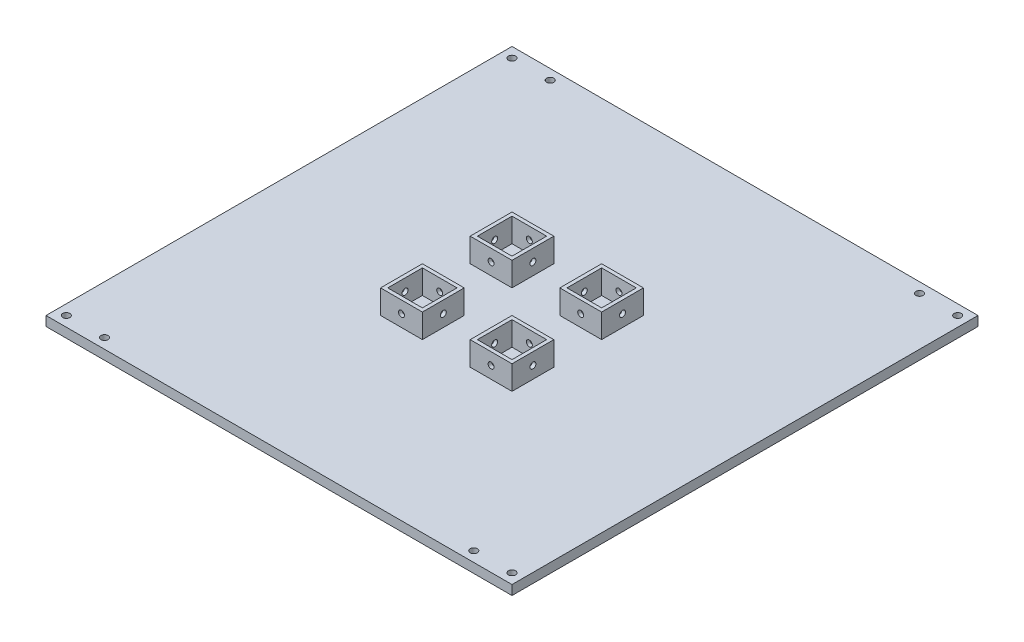
from build123d import *

# Parameters (mm, degrees)
SKETCH1_W                   = 195
SKETCH1_H                   = 195
BOSS_EXTRUDE1_DEPTH         = 4
SKETCH2_W                   = 17.5
SKETCH2_H                   = 17.5
BOSS_EXTRUDE2_DEPTH         = 10
SKETCH3_W                   = 14.5
SKETCH3_H                   = 14.5
CUT_EXTRUDE1_DEPTH          = 10
TAP_DRILL_FOR_M3X0_5_TAP1_D = 2.5
TAP_DRILL_FOR_M3X0_5_TAP2_D = 2.5
MIRROR2_COPY_1_SKETCH_W     = 17.5
MIRROR2_COPY_1_SKETCH_H     = 17.5
MIRROR2_COPY_1_DEPTH        = 10
MIRROR2_COPY_2_SKETCH_W     = 14.5
MIRROR2_COPY_2_SKETCH_H     = 14.5
MIRROR2_COPY_2_DEPTH        = 10
MIRROR2_COPY_3_D            = 2.5
MIRROR2_COPY_4_D            = 2.5
SKETCH8_R                   = 1.5
CUT_EXTRUDE2_DEPTH          = 4
MIRROR4_COPY_1_SKETCH_R     = 1.5
MIRROR4_COPY_1_DEPTH        = 4


with BuildPart() as part:
    # Sketch1 → Boss-Extrude1 (new body)
    with BuildSketch(Plane(origin=(0, 0, 0), x_dir=(1, 0, 0), z_dir=(0, 1, 0))):
        Rectangle(SKETCH1_W, SKETCH1_H)
    extrude(amount=BOSS_EXTRUDE1_DEPTH)

    # Sketch2 → Boss-Extrude2 (add)
    with BuildSketch(Plane(origin=(0, 4, 0), x_dir=(1, 0, 0), z_dir=(0, 1, 0))):
        with Locations((-18.75, 18.75)):
            Rectangle(SKETCH2_W, SKETCH2_H)
    boss_extrude2 = extrude(amount=BOSS_EXTRUDE2_DEPTH)

    # Sketch3 → Cut-Extrude1 (cut)
    with BuildSketch(Plane(origin=(0, 14, 0), x_dir=(1, 0, 0), z_dir=(0, 1, 0))):
        with Locations((-18.75, 18.75)):
            Rectangle(SKETCH3_W, SKETCH3_H)
    cut_extrude1 = extrude(amount=-CUT_EXTRUDE1_DEPTH, mode=Mode.SUBTRACT)

    # Tap Drill for M3x0.5 Tap1 (through all)
    with Locations(Plane.XY.offset(-10)):
        with Locations((-18.75, 9)):
            tap_drill_for_m3x0_5_tap1 = Hole(TAP_DRILL_FOR_M3X0_5_TAP1_D / 2)

    # Tap Drill for M3x0.5 Tap2 (through all)
    with Locations(Plane.ZY.offset(27.5)):
        with Locations((-18.75, 9)):
            tap_drill_for_m3x0_5_tap2 = Hole(TAP_DRILL_FOR_M3X0_5_TAP2_D / 2)

    # Mirror1: Boss-Extrude2, Cut-Extrude1, Tap Drill for M3x0.5 Tap1, Tap Drill for M3x0.5 Tap2 across plane
    add(boss_extrude2.mirror(Plane(origin=(0, 0, 0), x_dir=(1, 0, 0), z_dir=(0, 0, -1))))
    add(cut_extrude1.mirror(Plane(origin=(0, 0, 0), x_dir=(1, 0, 0), z_dir=(0, 0, -1))), mode=Mode.SUBTRACT)
    add(tap_drill_for_m3x0_5_tap1.mirror(Plane(origin=(0, 0, 0), x_dir=(1, 0, 0), z_dir=(0, 0, -1))), mode=Mode.SUBTRACT)
    add(tap_drill_for_m3x0_5_tap2.mirror(Plane(origin=(0, 0, 0), x_dir=(1, 0, 0), z_dir=(0, 0, -1))), mode=Mode.SUBTRACT)

    # Mirror2: Boss-Extrude2, Cut-Extrude1, Tap Drill for M3x0.5 Tap1, Tap Drill for M3x0.5 Tap2 across plane
    add(boss_extrude2.mirror(Plane.ZY))
    add(cut_extrude1.mirror(Plane.ZY), mode=Mode.SUBTRACT)
    add(tap_drill_for_m3x0_5_tap1.mirror(Plane.ZY), mode=Mode.SUBTRACT)
    add(tap_drill_for_m3x0_5_tap2.mirror(Plane.ZY), mode=Mode.SUBTRACT)

    # Mirror2 copy 1 sketch → Mirror2 copy 1 (add)
    with BuildSketch(Plane(origin=(0, 4, 0), x_dir=(-1, 0, 0), z_dir=(0, 1, 0))):
        with Locations((-18.75, 18.75)):
            Rectangle(MIRROR2_COPY_1_SKETCH_W, MIRROR2_COPY_1_SKETCH_H)
    extrude(amount=MIRROR2_COPY_1_DEPTH)

    # Mirror2 copy 2 sketch → Mirror2 copy 2 (cut)
    with BuildSketch(Plane(origin=(0, 14, 0), x_dir=(-1, 0, 0), z_dir=(0, 1, 0))):
        with Locations((-18.75, 18.75)):
            Rectangle(MIRROR2_COPY_2_SKETCH_W, MIRROR2_COPY_2_SKETCH_H)
    extrude(amount=-MIRROR2_COPY_2_DEPTH, mode=Mode.SUBTRACT)

    # Mirror2 copy 3 (through all)
    with Locations(Plane(origin=(0, 0, 10), x_dir=(-1, 0, 0), z_dir=(0, 0, -1))):
        with Locations((-18.75, 9)):
            Hole(MIRROR2_COPY_3_D / 2)

    # Mirror2 copy 4 (through all)
    with Locations(Plane(origin=(27.5, 0, 0), x_dir=(0, 0, -1), z_dir=(1, 0, 0))):
        with Locations((-18.75, 9)):
            Hole(MIRROR2_COPY_4_D / 2)

    # Sketch8 → Cut-Extrude2 (cut)
    with BuildSketch(Plane(origin=(0, 4, 0), x_dir=(1, 0, 0), z_dir=(0, 1, 0))):
        with Locations(Location((77.25, 93.25, 0), (0, 0, 270))):  # turned: the seam where the file's is
            Circle(SKETCH8_R)
        with Locations(Location((93.25, 93.25, 0), (0, 0, 270))):  # turned: the seam where the file's is
            Circle(SKETCH8_R)
    cut_extrude2 = extrude(amount=-CUT_EXTRUDE2_DEPTH, mode=Mode.SUBTRACT)

    # Mirror3: Cut-Extrude2 across plane
    add(cut_extrude2.mirror(Plane.ZY), mode=Mode.SUBTRACT)

    # Mirror4: Cut-Extrude2 across plane
    add(cut_extrude2.mirror(Plane(origin=(0, 0, 0), x_dir=(1, 0, 0), z_dir=(0, 0, -1))), mode=Mode.SUBTRACT)

    # Mirror4 copy 1 sketch → Mirror4 copy 1 (cut)
    with BuildSketch(Plane(origin=(0, 4, 0), x_dir=(-1, 0, 0), z_dir=(0, 1, 0))):
        with Locations(Location((77.25, 93.25, 0), (0, 0, 270))):  # turned: the seam where the file's is
            Circle(MIRROR4_COPY_1_SKETCH_R)
        with Locations(Location((93.25, 93.25, 0), (0, 0, 270))):  # turned: the seam where the file's is
            Circle(MIRROR4_COPY_1_SKETCH_R)
    extrude(amount=-MIRROR4_COPY_1_DEPTH, mode=Mode.SUBTRACT)


solid = part.part
